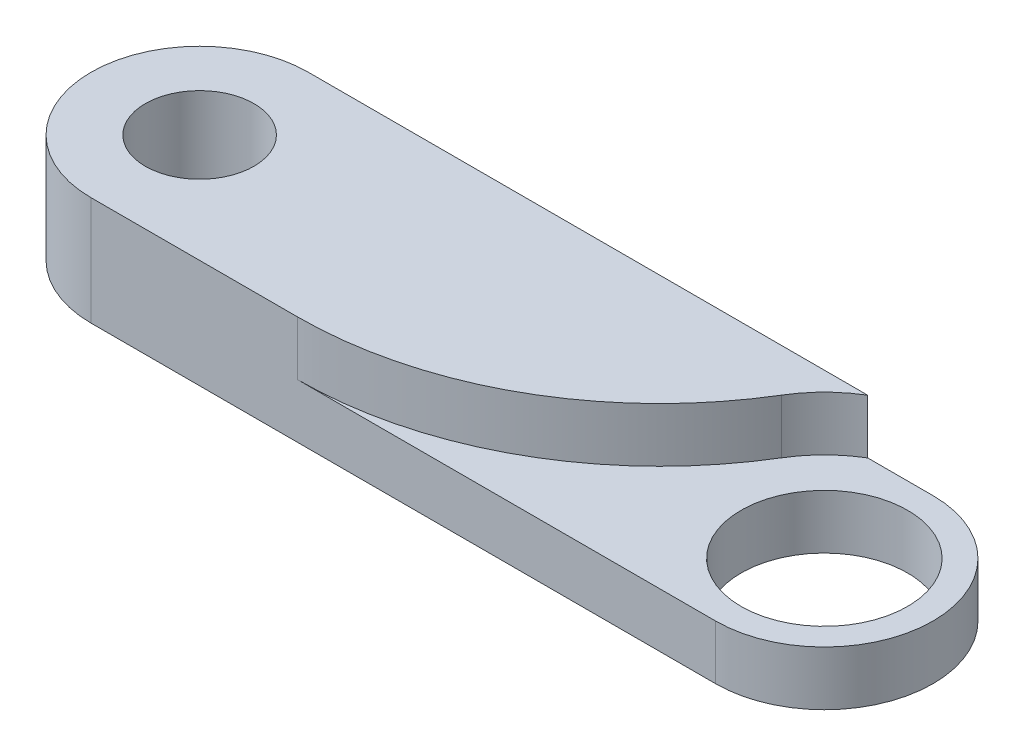
from build123d import *

# Parameters (mm, degrees)
SKETCH_1_R          = 3
SKETCH_1_R_2        = 4.6
EXTRUDE_1_DEPTH     = 6
SKETCH_3_R          = 7
CUT_EXTRUDE_1_DEPTH = 3
FILLET_1_R          = 20


with BuildPart() as part:
    # ｽｹｯﾁ1 → ﾎﾞｽ - 押し出し1 (new body)
    with BuildSketch(Plane(origin=(0, 0, 0), x_dir=(1, 0, 0), z_dir=(0, 1, 0))):
        with BuildLine():
            Line((-17.25, 6), (17.25, 6))
            ThreePointArc((17.25, 6), (23.25, 0), (17.25, -6))
            Line((17.25, -6), (-17.25, -6))
            ThreePointArc((-17.25, -6), (-23.25, 0), (-17.25, 6))
        make_face()
        with Locations((-17.25, 0)):
            Circle(SKETCH_1_R, mode=Mode.SUBTRACT)
        with Locations((17.25, 0)):
            Circle(SKETCH_1_R_2, mode=Mode.SUBTRACT)
    extrude(amount=EXTRUDE_1_DEPTH)

    # ｽｹｯﾁ3 → ｶｯﾄ - 押し出し1 (cut)
    with BuildSketch(Plane(origin=(0, 6, 0), x_dir=(1, 0, 0), z_dir=(0, 1, 0))):
        with Locations((17.25, 0)):
            Circle(SKETCH_3_R)
    extrude(amount=-CUT_EXTRUDE_1_DEPTH, mode=Mode.SUBTRACT)

    # ﾌｨﾚｯﾄ1
    fillet_1_edges = [part.edges().sort_by_distance(p)[0] for p in [
        (13.644448725, 4.5, 6),
    ]]
    fillet(fillet_1_edges, radius=FILLET_1_R)


solid = part.part
